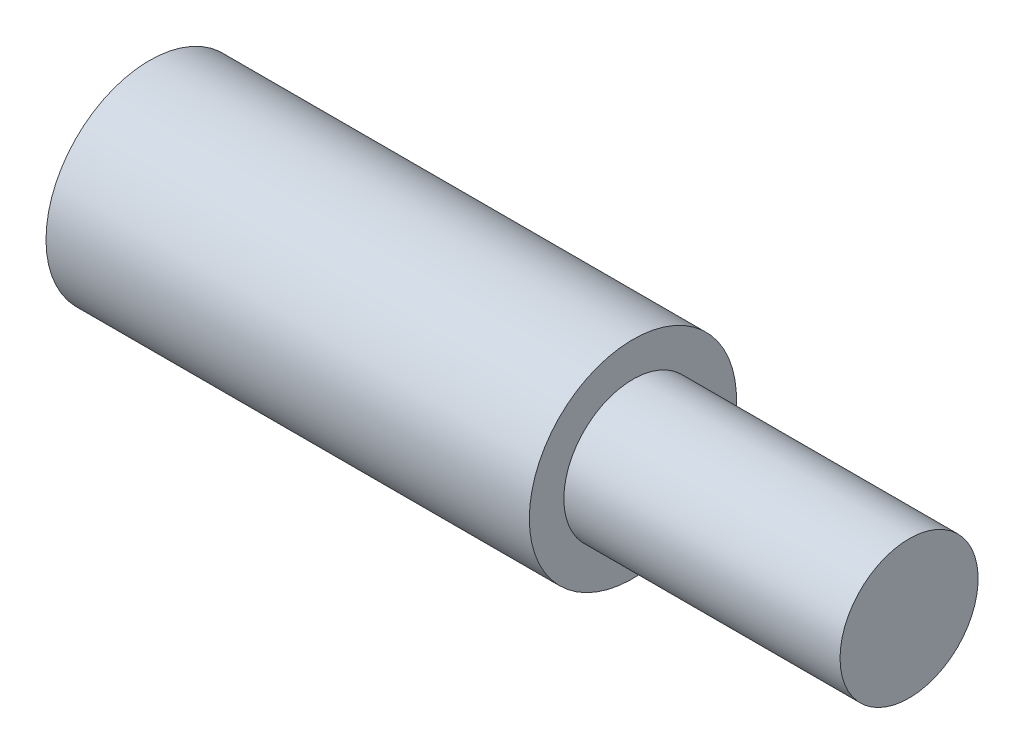
from build123d import *


with BuildPart() as part:
    # Sketch1 → Revolve1 (revolve)
    with BuildSketch(Plane.XY):
        Polygon((0, 0), (0, 1.5), (7, 1.5), (7, 1), (11, 1), (11, 0), align=None)
    revolve(axis=Axis((0, 0, 0), (1, 0, 0)))


solid = part.part
